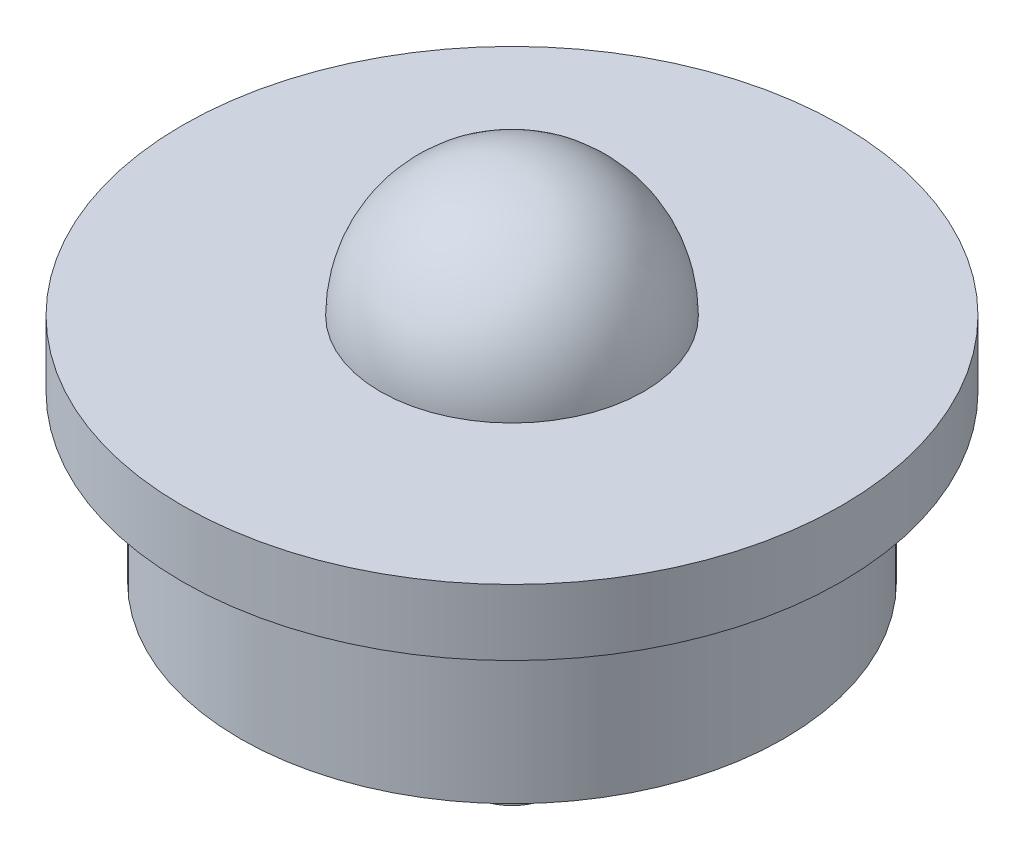
from build123d import *

# Parameters (mm, degrees)
SKETCH1_R           = 26.19375
BOSS_EXTRUDE1_DEPTH = 22.225
SKETCH2_R           = 31.75
BOSS_EXTRUDE2_DEPTH = 6.35
SKETCH4_R           = 3.96875
BOSS_EXTRUDE3_DEPTH = 15.875


with BuildPart() as part:
    # Sketch1 → Boss-Extrude1 (new body)
    with BuildSketch(Plane(origin=(0, 0, 0), x_dir=(1, 0, 0), z_dir=(0, 1, 0))):
        Circle(SKETCH1_R)
    extrude(amount=BOSS_EXTRUDE1_DEPTH)

    # Sketch2 → Boss-Extrude2 (add)
    with BuildSketch(Plane(origin=(0, 22.225, 0), x_dir=(1, 0, 0), z_dir=(0, 1, 0))):
        Circle(SKETCH2_R)
    extrude(amount=-BOSS_EXTRUDE2_DEPTH)

    # Sketch3 → Revolve1 (revolve)
    with BuildSketch(Plane(origin=(0, 22.225, 0), x_dir=(1, 0, 0), z_dir=(0, 1, 0))):
        with BuildLine():
            Line((0, -12.7), (0, 12.7))
            ThreePointArc((0, 12.7), (12.7, 0), (0, -12.7))
        make_face()
    revolve(axis=Axis((0, 22.225, -45.379060403), (0, 0, 1)))

    # Sketch4 → Boss-Extrude3 (add)
    with BuildSketch(Plane.XZ):
        Circle(SKETCH4_R)
    extrude(amount=BOSS_EXTRUDE3_DEPTH)


solid = part.part
